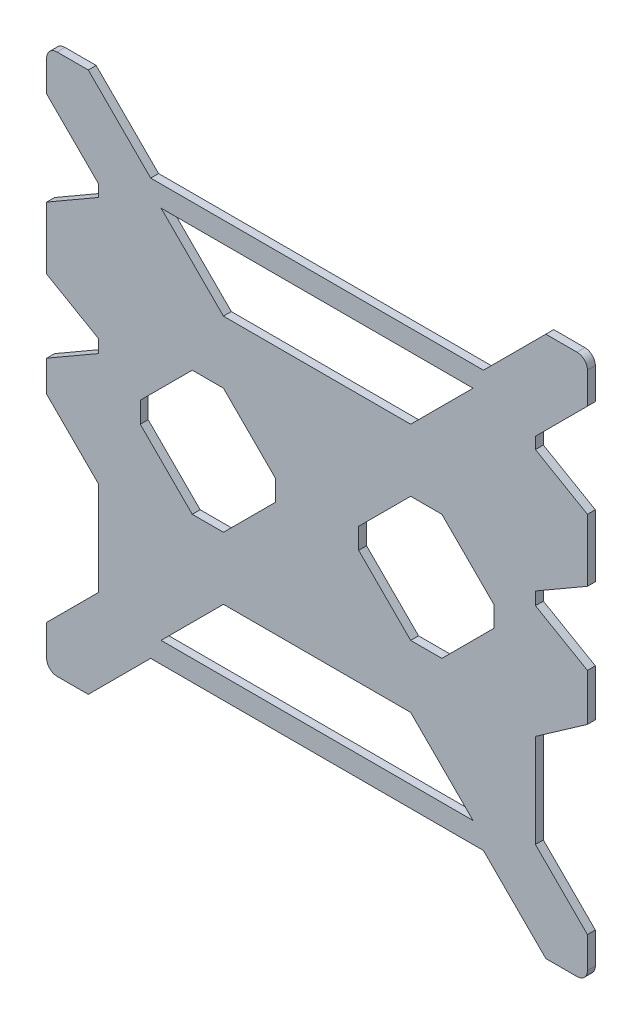
from build123d import *

# Parameters (mm, degrees)
BOSS_EXTRUDE1_DEPTH = 2.413
SCALE1_SCALE        = 0.666666667


with BuildPart() as part:
    # Model → Boss-Extrude1 (new body, symmetric)
    with BuildSketch(Plane.XY):
        with BuildLine():
            Line((-290.681304326, -31.2683), (-258.931304326, -12.937428953))
            Line((-258.931304326, -12.937428953), (-258.931304326, -5.149171047))
            Line((-258.931304326, -5.149171047), (-290.681304326, 13.1817))
            Line((-290.681304326, 13.1817), (-290.681304326, 51.2817))
            Line((-290.681304326, 51.2817), (-258.931304326, 69.612571047))
            Line((-258.931304326, 69.612571047), (-258.931304326, 76.6817))
            Line((-258.931304326, 76.6817), (-290.681304326, 108.4317))
            Line((-290.681304326, 108.4317), (-290.681304326, 127.4817))
            ThreePointArc((-290.681304326, 127.4817), (-288.821432386, 131.971828061), (-284.331304326, 133.8317))
            Line((-284.331304326, 133.8317), (-265.281304326, 133.8317))
            Line((-265.281304326, 133.8317), (-227.181304326, 95.7317))
            Line((-227.181304326, 95.7317), (-23.981304326, 95.7317))
            Line((-23.981304326, 95.7317), (14.118695674, 133.8317))
            Line((14.118695674, 133.8317), (33.168695674, 133.8317))
            ThreePointArc((33.168695674, 133.8317), (37.658823735, 131.971828061), (39.518695674, 127.4817))
            Line((39.518695674, 127.4817), (39.518695674, 108.4317))
            Line((39.518695674, 108.4317), (7.768695674, 76.6817))
            Line((7.768695674, 76.6817), (7.768695674, 69.612571047))
            Line((7.768695674, 69.612571047), (39.518695674, 51.2817))
            Line((39.518695674, 51.2817), (39.518695674, 13.1817))
            Line((39.518695674, 13.1817), (7.768695674, -5.149171047))
            Line((7.768695674, -5.149171047), (7.768695674, -12.937428953))
            Line((7.768695674, -12.937428953), (39.518695674, -31.2683))
            Line((39.518695674, -31.2683), (39.518695674, -59.836710662))
            Line((39.518695674, -59.836710662), (10.464640386, -80.18057919))
            Line((10.464640386, -80.18057919), (7.768695674, -82.0683))
            Line((7.768695674, -82.0683), (7.768695674, -139.2183))
            Line((7.768695674, -139.2183), (39.518695674, -170.9683))
            Line((39.518695674, -170.9683), (39.518695674, -190.0183))
            ThreePointArc((39.518695674, -190.0183), (37.658823735, -194.508428061), (33.168695674, -196.3683))
            Line((33.168695674, -196.3683), (14.118695674, -196.3683))
            Line((14.118695674, -196.3683), (-23.981304326, -158.2683))
            Line((-23.981304326, -158.2683), (-227.181304326, -158.2683))
            Line((-227.181304326, -158.2683), (-265.281304326, -196.3683))
            Line((-265.281304326, -196.3683), (-284.331304326, -196.3683))
            ThreePointArc((-284.331304326, -196.3683), (-288.821432386, -194.508428061), (-290.681304326, -190.0183))
            Line((-290.681304326, -190.0183), (-290.681304326, -170.9683))
            Line((-290.681304326, -170.9683), (-258.931304326, -139.2183))
            Line((-258.931304326, -139.2183), (-258.931304326, -82.0683))
            Line((-258.931304326, -82.0683), (-290.681304326, -50.3183))
            Line((-290.681304326, -50.3183), (-290.681304326, -31.2683))
        make_face()
        Polygon((-30.331304326, -145.5683), (-68.431304326, -107.4683), (-182.731304326, -107.4683), (-220.831304326, -145.5683), align=None, mode=Mode.SUBTRACT)
        Polygon((-220.831304326, 83.0317), (-182.731304326, 44.9317), (-68.431304326, 44.9317), (-30.331304326, 83.0317), align=None, mode=Mode.SUBTRACT)
        Polygon((-201.781304326, -69.3683), (-233.531304326, -37.6183), (-233.531304326, -24.9183), (-201.781304326, 6.8317), (-182.731304326, 6.8317), (-150.981304326, -24.9183), (-150.981304326, -37.6183), (-182.731304326, -69.3683), align=None, mode=Mode.SUBTRACT)
        Polygon((-100.181304326, -37.6183), (-100.181304326, -24.9183), (-68.431304326, 6.8317), (-49.381304326, 6.8317), (-17.631304326, -24.9183), (-17.631304326, -37.6183), (-49.381304326, -69.3683), (-68.431304326, -69.3683), align=None, mode=Mode.SUBTRACT)
    extrude(amount=BOSS_EXTRUDE1_DEPTH, both=True)


with BuildPart() as part_1:
    # Scale1: scaled about (-125.200156118, -28.252377371, 0)
    add(part.part.scale(SCALE1_SCALE).moved(Location((-41.733385373, -9.417459124, 0))))


solid = part_1.part
